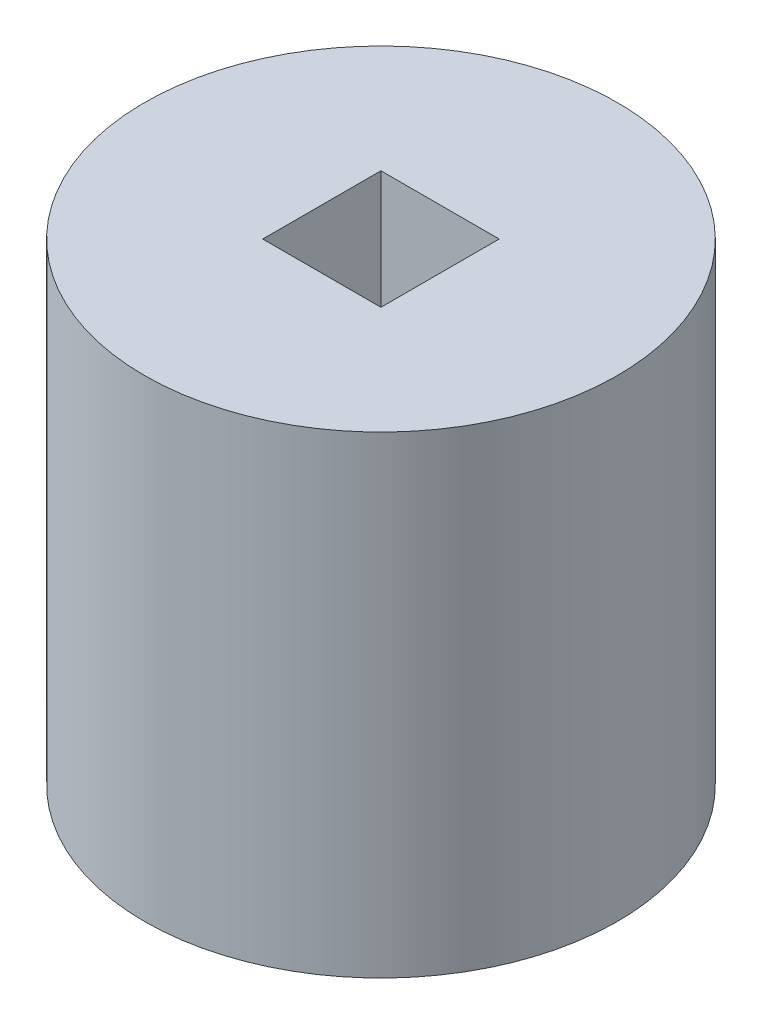
from build123d import *

# Parameters (mm, degrees)
SKETCH3_R           = 50
SKETCH3_W           = 25
SKETCH3_H           = 25
BOSS_EXTRUDE1_DEPTH = 100


with BuildPart() as part:
    # Sketch3 → Boss-Extrude1 (new body)
    with BuildSketch(Plane(origin=(0, 0, 0), x_dir=(1, 0, 0), z_dir=(0, 1, 0))):
        Circle(SKETCH3_R)
        Rectangle(SKETCH3_W, SKETCH3_H, mode=Mode.SUBTRACT)
    extrude(amount=BOSS_EXTRUDE1_DEPTH)


solid = part.part
